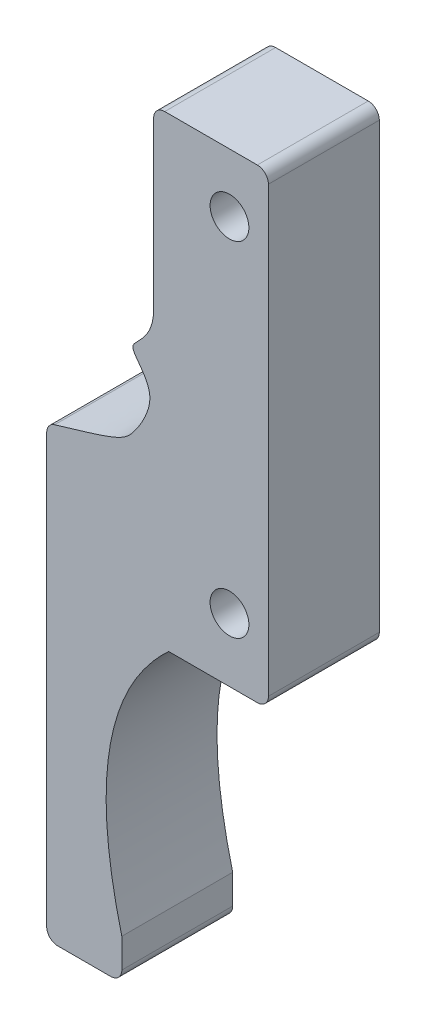
from build123d import *

# Parameters (mm, degrees)
SKETCH1_R           = 1.75
BOSS_EXTRUDE1_DEPTH = 10


with BuildPart() as part:
    # Sketch1 → Boss-Extrude1 (new body)
    with BuildSketch(Plane.XY):
        with BuildLine():
            Line((73.053682236, 111.958146332), (81.407497616, 111.958146332))
            ThreePointArc((81.407497616, 111.958146332), (82.114604398, 111.665253114), (82.407497616, 110.958146332))
            Line((82.407497616, 110.958146332), (82.407497616, 70.958146332))
            ThreePointArc((82.407497616, 70.958146332), (82.114604398, 70.251039551), (81.407497616, 69.958146332))
            Line((81.407497616, 69.958146332), (73.407497616, 69.958146332))
            add(Edge.make_bspline(
                [(69.182828204, 45.599922824), (64.94615604, 62.131405374), (73.407497616, 69.958146332)],
                knots=[0, 0, 0, 1, 1, 1], degree=2))
            Line((69.182828204, 45.599922824), (69.182828204, 42.958146332))
            ThreePointArc((69.182828204, 42.958146332), (68.889934985, 42.251039551), (68.182828204, 41.958146332))
            Line((68.182828204, 41.958146332), (63.407497616, 41.958146332))
            ThreePointArc((63.407497616, 41.958146332), (62.700390835, 42.251039551), (62.407497616, 42.958146332))
            Line((62.407497616, 42.958146332), (62.407497616, 81.5661721))
            ThreePointArc((62.407497616, 81.5661721), (62.605849898, 82.163968834), (63.122219487, 82.524616876))
            add(Edge.make_bspline(
                [(63.122219487, 82.524616876), (67.821663275, 83.923391816), (69.297708233, 84.346422766), (70.793118302, 86.197707517), (72.619735364, 89.442432773), (70.361342971, 91.342709778), (70.002118619, 92.666400755), (72.053682236, 93.570600079), (72.053682236, 96.019092409)],
                knots=[0.012469808, 0.012469808, 0.012469808, 0.012469808, 0.267445708, 0.317679419, 0.514806914, 0.751762402, 0.800281711, 1, 1, 1, 1], degree=3))
            Line((72.053682236, 96.019092409), (72.053682236, 110.958146332))
            ThreePointArc((72.053682236, 110.958146332), (72.346575455, 111.665253114), (73.053682236, 111.958146332))
        make_face()
        with Locations((78.893605795, 106.672950269)):
            Circle(SKETCH1_R, mode=Mode.SUBTRACT)
        with Locations((78.893605795, 75.672950269)):
            Circle(SKETCH1_R, mode=Mode.SUBTRACT)
    extrude(amount=BOSS_EXTRUDE1_DEPTH)


solid = part.part
